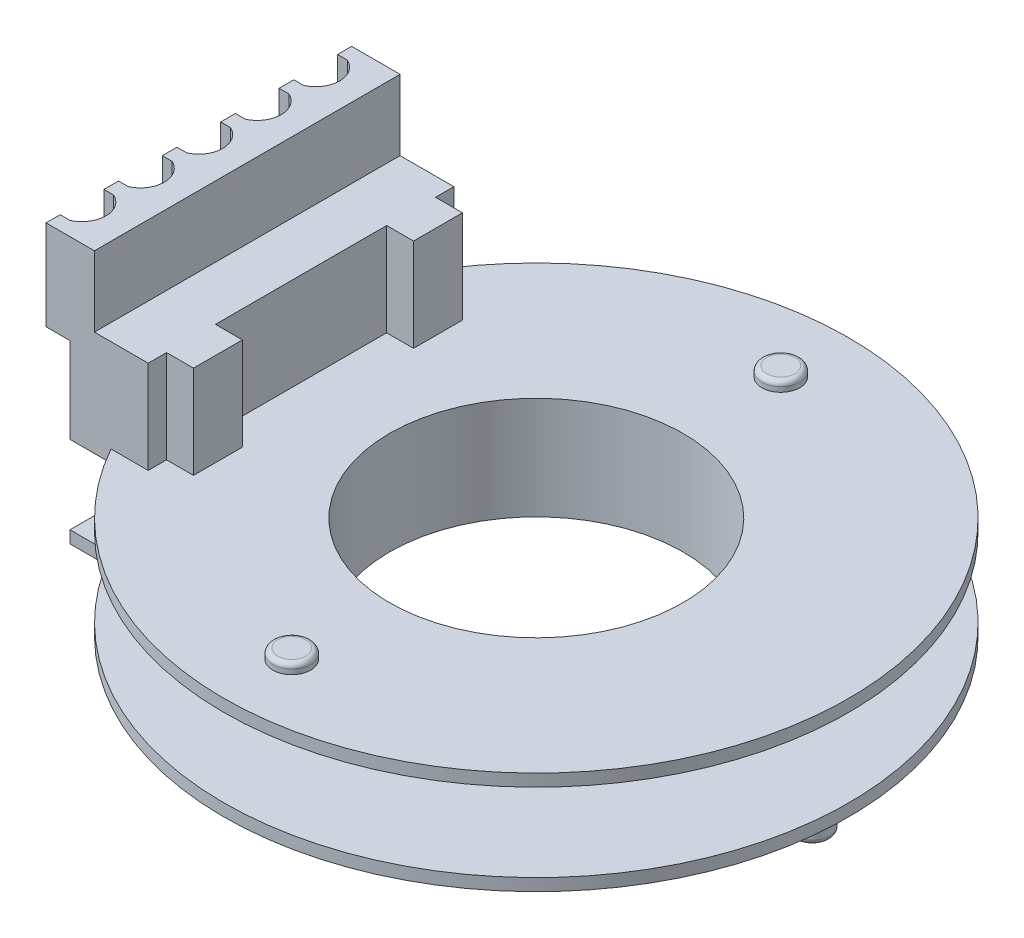
from build123d import *

# Parameters (mm, degrees)
SKETCH_2_W           = 3.35
SKETCH_2_H           = 12.5
EXTRUDE_1_DEPTH      = 3.8
EXTRUDE_1_DEPTH_BACK = 0.5
SKETCH_4_W           = 0.95
SKETCH_4_H           = 12.5
EXTRUDE_2_DEPTH      = 3.8
SKETCH_6_W           = 1.1
SKETCH_6_H           = 0.75
SKETCH_6_H_2         = 7
CUT_EXTRUDE_1_DEPTH  = 3.8
SKETCH_7_W           = 1.98
SKETCH_7_H           = 12.5
EXTRUDE_3_DEPTH      = 2.88
EXTRUDE_3_DEPTH_BACK = 0.8
SKETCH_8_R           = 0.425
EXTRUDE_4_DEPTH      = 2.4
EXTRUDE_4_2_DEPTH    = 2.4
EXTRUDE_4_3_DEPTH    = 2.4
CUT_EXTRUDE_2_DEPTH  = 3.68
SKETCH_10_R          = 0.775
EXTRUDE_5_DEPTH      = 0.4
SKETCH_11_R          = 0.775
SKETCH_11_R_2        = 0.725
EXTRUDE_6_DEPTH      = 0.4
SKETCH_12_R          = 0.725
EXTRUDE_7_DEPTH      = 0.85
FILLET_1_R           = 0.2
SKETCH_13_W          = 2.325
SKETCH_13_H          = 12.5
EXTRUDE_8_DEPTH      = 0.5


with BuildPart() as part:
    # Эскиз1 → Повернуть1 (revolve)
    with BuildSketch(Plane.XY):
        Polygon((7, 1.6), (7, -1.6), (12.775, -1.6), (12.775, -2.1), (6, -2.1), (6, 2.1), (12.775, 2.1), (12.775, 1.6), align=None)
    revolve(axis=Axis((0, 2.1, 0), (0, -1, 0)))

    # Эскиз2 → Бобышка-Вытянуть1 (add, two sides)
    with BuildSketch(Plane(origin=(0, 2.1, 0), x_dir=(1, 0, 0), z_dir=(0, 1, 0))) as extrude_1_sk:
        with Locations((-11.145, 0)):
            Rectangle(SKETCH_2_W, SKETCH_2_H)
    extrude(amount=EXTRUDE_1_DEPTH)
    extrude(extrude_1_sk.sketch, amount=-EXTRUDE_1_DEPTH_BACK)

    # Эскиз4 → Бобышка-Вытянуть2 (add)
    with BuildSketch(Plane(origin=(0, 5.9, 0), x_dir=(1, 0, 0), z_dir=(0, 1, 0))):
        with Locations((-8.995, 0)):
            Rectangle(SKETCH_4_W, SKETCH_4_H)
    extrude(amount=-EXTRUDE_2_DEPTH)

    # Эскиз6 → Вырез-Вытянуть1 (cut)
    with BuildSketch(Plane(origin=(0, 5.9, 0), x_dir=(1, 0, 0), z_dir=(0, 1, 0))):
        with Locations((-9.07, 5.875)):
            Rectangle(SKETCH_6_W, SKETCH_6_H)
        with Locations((-9.07, 0)):
            Rectangle(SKETCH_6_W, SKETCH_6_H_2)
        with Locations((-9.07, -5.875)):
            Rectangle(SKETCH_6_W, SKETCH_6_H)
    extrude(amount=-CUT_EXTRUDE_1_DEPTH, mode=Mode.SUBTRACT)

    # Эскиз7 → Бобышка-Вытянуть3 (add, two sides)
    with BuildSketch(Plane(origin=(0, 5.9, 0), x_dir=(1, 0, 0), z_dir=(0, 1, 0))) as extrude_3_sk:
        with Locations((-12.81, 0)):
            Rectangle(SKETCH_7_W, SKETCH_7_H)
    extrude(amount=EXTRUDE_3_DEPTH)
    extrude(extrude_3_sk.sketch, amount=-EXTRUDE_3_DEPTH_BACK)

    # Эскиз9 → Вырез-Вытянуть2 (cut)
    with BuildSketch(Plane(origin=(0, 8.78, 0), x_dir=(1, 0, 0), z_dir=(0, 1, 0))):
        with BuildLine():
            Line((-13.4, 3.28395231), (-13.8, 3.28395231))
            Line((-13.8, 3.28395231), (-13.8, 1.49465077))
            Line((-13.8, 1.49465077), (-13.4, 1.49465077))
            ThreePointArc((-13.4, 1.49465077), (-12.82, 2.38930154), (-13.4, 3.28395231))
        make_face()
        with BuildLine():
            Line((-13.4, -1.49465077), (-13.8, -1.49465077))
            Line((-13.8, -1.49465077), (-13.8, -3.28395231))
            Line((-13.8, -3.28395231), (-13.4, -3.28395231))
            ThreePointArc((-13.4, -3.28395231), (-12.82, -2.38930154), (-13.4, -1.49465077))
        make_face()
        with BuildLine():
            Line((-13.4, 0.89465077), (-13.8, 0.89465077))
            Line((-13.8, 0.89465077), (-13.8, -0.89465077))
            Line((-13.8, -0.89465077), (-13.4, -0.89465077))
            ThreePointArc((-13.4, -0.89465077), (-12.82, 0), (-13.4, 0.89465077))
        make_face()
        with BuildLine():
            Line((-13.4, 5.673253849), (-13.8, 5.673253849))
            Line((-13.8, 5.673253849), (-13.8, 3.88395231))
            Line((-13.8, 3.88395231), (-13.4, 3.88395231))
            ThreePointArc((-13.4, 3.88395231), (-12.82, 4.778603079), (-13.4, 5.673253849))
        make_face()
        with BuildLine():
            Line((-13.4, -3.88395231), (-13.8, -3.88395231))
            Line((-13.8, -3.88395231), (-13.8, -5.673253849))
            Line((-13.8, -5.673253849), (-13.4, -5.673253849))
            ThreePointArc((-13.4, -5.673253849), (-12.82, -4.778603079), (-13.4, -3.88395231))
        make_face()
    extrude(amount=-CUT_EXTRUDE_2_DEPTH, mode=Mode.SUBTRACT)

    # Эскиз10 → Бобышка-Вытянуть5 (add)
    with BuildSketch(Plane(origin=(0, 2.1, 0), x_dir=(1, 0, 0), z_dir=(0, 1, 0))):
        with Locations((0, 10)):
            Circle(SKETCH_10_R)
        with Locations((0, -10)):
            Circle(SKETCH_10_R)
    extrude(amount=EXTRUDE_5_DEPTH)

    # Эскиз11 → Бобышка-Вытянуть6 (add)
    with BuildSketch(Plane.XZ.offset(2.1)):
        with Locations((0, -10)):
            Circle(SKETCH_11_R)
        with Locations((0, 10)):
            Circle(SKETCH_11_R)
        with Locations((11.28, 0)):
            Circle(SKETCH_11_R_2)
        with Locations((-11.22, 5.35)):
            Circle(SKETCH_11_R_2)
        with Locations((-11.22, -5.35)):
            Circle(SKETCH_11_R_2)
    extrude(amount=EXTRUDE_6_DEPTH)

    # Эскиз12 → Бобышка-Вытянуть7 (add)
    with BuildSketch(Plane.XZ.offset(2.5)):
        with Locations((11.28, 0)):
            Circle(SKETCH_12_R)
        with Locations((-11.22, -5.35)):
            Circle(SKETCH_12_R)
        with Locations((-11.22, 5.35)):
            Circle(SKETCH_12_R)
    extrude(amount=EXTRUDE_7_DEPTH)

    # Скругление1
    fillet_1_edges = [part.edges().sort_by_distance(p)[0] for p in [
        (-0.775, 2.5, -10),
        (-0.775, 2.5, 10),
        (-0.775, -2.5, -10),
        (-0.775, -2.5, 10),
        (10.555, -3.35, 0),
        (-11.945, -3.35, -5.35),
        (-11.945, -3.35, 5.35),
    ]]
    fillet(fillet_1_edges, radius=FILLET_1_R)

    # Эскиз13 → Бобышка-Вытянуть8 (add)
    with BuildSketch(Plane.XZ.offset(2.1)):
        with Locations((-11.6575, 0)):
            Rectangle(SKETCH_13_W, SKETCH_13_H)
    extrude(amount=-EXTRUDE_8_DEPTH)


with BuildPart() as body_2:
    # Эскиз8 → Бобышка-Вытянуть4 (new body)
    with BuildSketch(Plane.ZY.offset(12.82)):
        with Locations((-2.4, 2.45)):
            Circle(SKETCH_8_R)
    extrude(amount=EXTRUDE_4_DEPTH)


with BuildPart() as body_3:
    # Эскиз8 → Extrude 4 2 (new body)
    with BuildSketch(Plane.ZY.offset(12.82)):
        with Locations((0, 2.45)):
            Circle(SKETCH_8_R)
    extrude(amount=EXTRUDE_4_2_DEPTH)


with BuildPart() as body_4:
    # Эскиз8 → Extrude 4 3 (new body)
    with BuildSketch(Plane.ZY.offset(12.82)):
        with Locations((2.4, 2.45)):
            Circle(SKETCH_8_R)
    extrude(amount=EXTRUDE_4_3_DEPTH)


solid = Compound([part.part, body_2.part, body_3.part, body_4.part])
